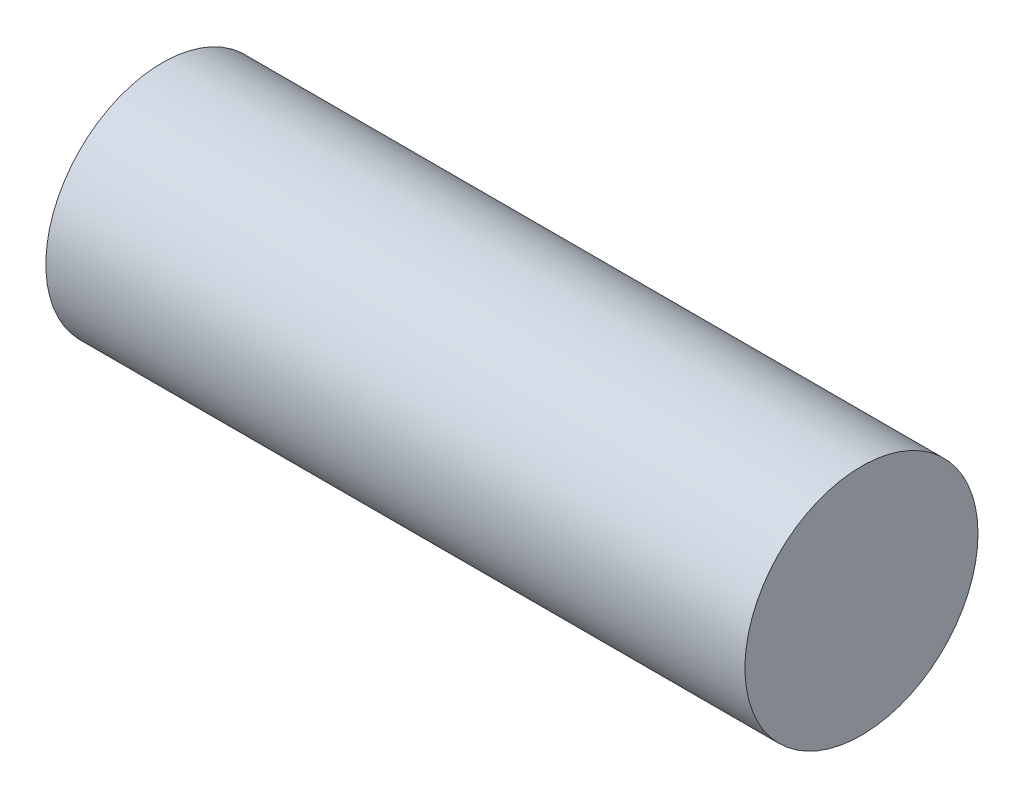
from build123d import *

# Parameters (mm, degrees)
SKETCH1_R           = 5
BOSS_EXTRUDE1_DEPTH = 30


with BuildPart() as part:
    # Sketch1 → Boss-Extrude1 (new body)
    with BuildSketch(Plane(origin=(0, 0, 0), x_dir=(0, 0, -1), z_dir=(1, 0, 0))):
        Circle(SKETCH1_R)
    extrude(amount=BOSS_EXTRUDE1_DEPTH)


solid = part.part
